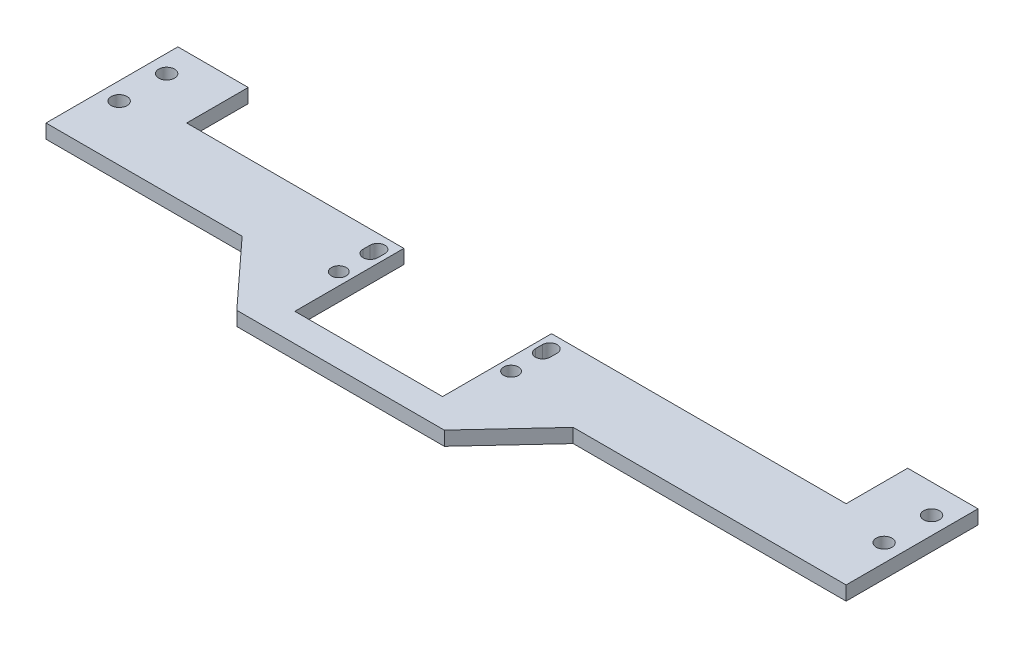
from build123d import *

# Parameters (mm, degrees)
SKETCH_1_R      = 2.25
SKETCH_1_R_2    = 2.1
EXTRUDE_1_DEPTH = 4
EXTRUDE_2_DEPTH = 4


with BuildPart() as part:
    # 草图1 → 凸台-拉伸1 (new body)
    with BuildSketch(Plane(origin=(0, 0, 0), x_dir=(1, 0, 0), z_dir=(0, 1, 0))):
        Polygon((-83.136892884, -5.45556523), (-125.136892884, -5.45556523), (-125.136892884, 25.54443477), (-186.886892884, 25.54443477), (-186.886892884, 43.04443477), (-206.886892884, 43.04443477), (-206.886892884, 5.54443477), (-189.553457543, 5.54443477), (-133.636892884, 5.54443477), (-133.636892884, -13.45556523), (-74.636892884, -13.45556523), (-74.636892884, 5.54443477), (1.279671775, 5.54443477), (20.613107116, 5.54443477), (20.613107116, 13.09443477), (20.613107116, 43.04443477), (0.613107116, 43.04443477), (0.613107116, 25.54443477), (-74.636892884, 25.54443477), (-83.136892884, 25.54443477), align=None)
        with Locations((15.613107116, 34.84443477)):
            Circle(SKETCH_1_R, mode=Mode.SUBTRACT)
        with Locations((15.613107116, 21.34443477)):
            Circle(SKETCH_1_R, mode=Mode.SUBTRACT)
        with Locations((-79.636892884, 10.54443477)):
            Circle(SKETCH_1_R_2, mode=Mode.SUBTRACT)
        with Locations((-128.636892884, 10.54443477)):
            Circle(SKETCH_1_R_2, mode=Mode.SUBTRACT)
        with Locations((-201.886892884, 34.84443477)):
            Circle(SKETCH_1_R, mode=Mode.SUBTRACT)
        with Locations((-201.886892884, 21.34443477)):
            Circle(SKETCH_1_R, mode=Mode.SUBTRACT)
        with BuildLine():
            Line((-81.736892884, 21.54443477), (-81.736892884, 19.54443477))
            ThreePointArc((-81.736892884, 19.54443477), (-79.636892884, 17.44443477), (-77.536892884, 19.54443477))
            Line((-77.536892884, 19.54443477), (-77.536892884, 21.54443477))
            ThreePointArc((-77.536892884, 21.54443477), (-79.636892884, 23.64443477), (-81.736892884, 21.54443477))
        make_face(mode=Mode.SUBTRACT)
        with BuildLine():
            Line((-130.736892884, 21.54443477), (-130.736892884, 19.54443477))
            ThreePointArc((-130.736892884, 19.54443477), (-128.636892884, 17.44443477), (-126.536892884, 19.54443477))
            Line((-126.536892884, 19.54443477), (-126.536892884, 21.54443477))
            ThreePointArc((-126.536892884, 21.54443477), (-128.636892884, 23.64443477), (-130.736892884, 21.54443477))
        make_face(mode=Mode.SUBTRACT)
    extrude(amount=EXTRUDE_1_DEPTH)

    # 草图4 → 凸台-拉伸2 (add)
    with BuildSketch(Plane(origin=(0, 4, 0), x_dir=(1, 0, 0), z_dir=(0, 1, 0))):
        Polygon((-133.636892884, -13.45556523), (-151.115738533, 5.54443477), (-133.636892884, 5.54443477), align=None)
        Polygon((-74.636892884, -13.45556523), (-74.636892884, 5.54443477), (-56.979755625, 5.54443477), align=None)
    extrude(amount=-EXTRUDE_2_DEPTH)


solid = part.part
